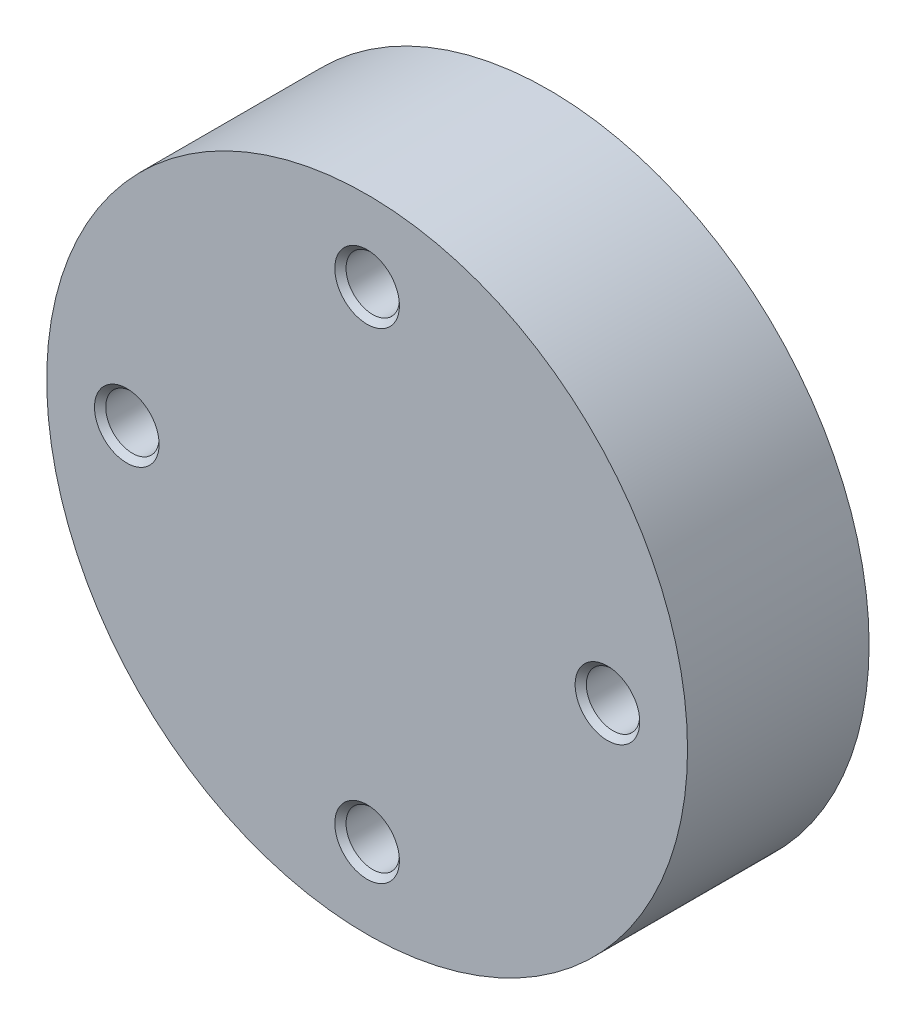
from build123d import *

# Parameters (mm, degrees)
SKETCH1_R                   = 30
BOSS_EXTRUDE1_DEPTH         = 17
SKETCH1_3_R                 = 15
CUT_EXTRUDE1_DEPTH          = 15
M6_TAPPED_HOLE1_D           = 5
M6_TAPPED_HOLE1_DEPTH       = 9
M6_TAPPED_HOLE1_CSINK_D     = 6.05
M6_TAPPED_HOLE1_CSINK_ANGLE = 90
M6_TAPPED_HOLE1_TIP         = 1.502151548


with BuildPart() as part:
    # Sketch1 → Boss-Extrude1 (new body)
    with BuildSketch(Plane.XY):
        Circle(SKETCH1_R)
    extrude(amount=BOSS_EXTRUDE1_DEPTH)

    # Sketch1_3 → Cut-Extrude1 (cut)
    with BuildSketch(Plane.XY):
        Circle(SKETCH1_3_R)
    extrude(amount=CUT_EXTRUDE1_DEPTH, mode=Mode.SUBTRACT)

    # M6 Tapped Hole1
    with Locations(Plane.XY.offset(17)):
        with Locations((0, -22.5), (22.5, 0), (0, 22.5), (-22.5, 0)):
            CounterSinkHole(M6_TAPPED_HOLE1_D / 2, M6_TAPPED_HOLE1_CSINK_D / 2, depth=M6_TAPPED_HOLE1_DEPTH, counter_sink_angle=M6_TAPPED_HOLE1_CSINK_ANGLE)
            with Locations((0, 0, -(M6_TAPPED_HOLE1_DEPTH + M6_TAPPED_HOLE1_TIP / 2))):  # 118° drill point
                Cone(0, M6_TAPPED_HOLE1_D / 2, M6_TAPPED_HOLE1_TIP, mode=Mode.SUBTRACT)


solid = part.part
